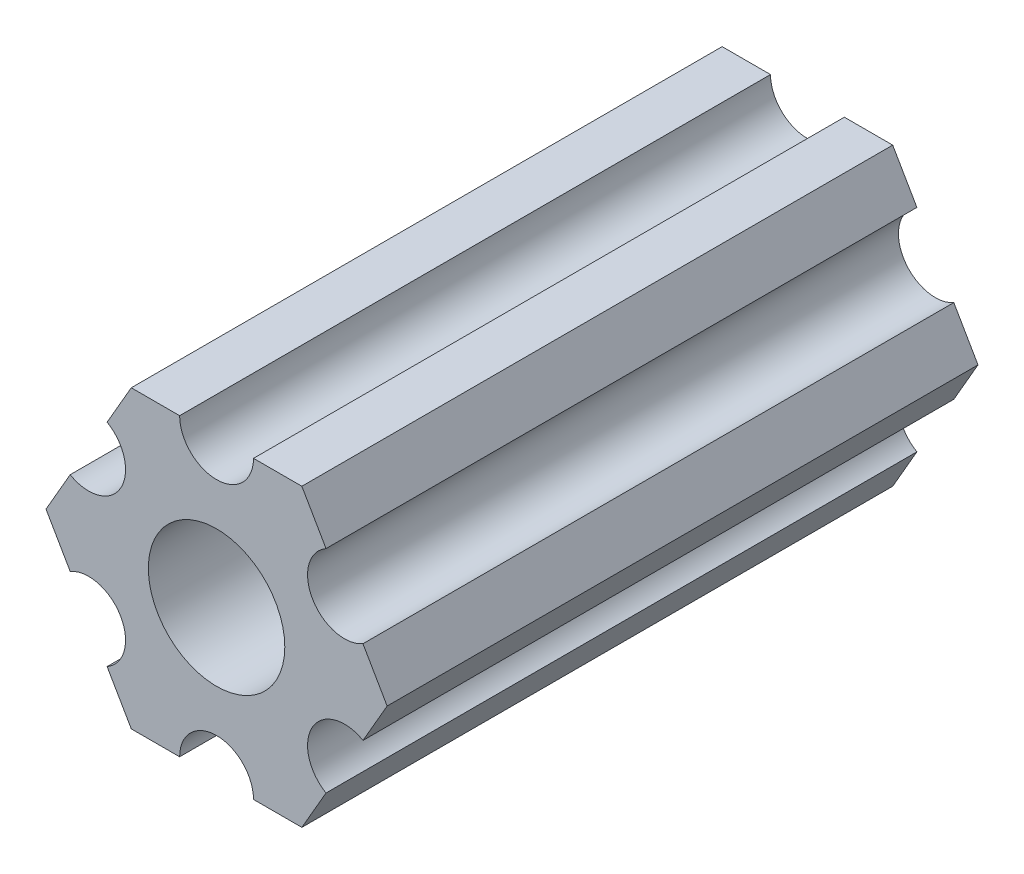
from build123d import *

# Parameters (mm, degrees)
SKETCH1_R           = 2.9337
BOSS_EXTRUDE1_DEPTH = 25.4


with BuildPart() as part:
    # Sketch1 → Boss-Extrude1 (new body)
    with BuildSketch(Plane.XY):
        with BuildLine():
            Line((-4.705511314, -4.549815329), (-3.666174209, -6.35))
            Line((-3.666174209, -6.35), (-1.5875, -6.35))
            ThreePointArc((-1.5875, -6.35), (0, -4.7625), (1.5875, -6.35))
            Line((1.5875, -6.35), (3.666174209, -6.35))
            Line((3.666174209, -6.35), (4.705511314, -4.549815329))
            ThreePointArc((4.705511314, -4.549815329), (4.124445986, -2.38125), (6.293011314, -1.800184671))
            Line((6.293011314, -1.800184671), (7.332348419, 0))
            Line((7.332348419, 0), (6.293011314, 1.800184671))
            ThreePointArc((6.293011314, 1.800184671), (4.124445986, 2.38125), (4.705511314, 4.549815329))
            Line((4.705511314, 4.549815329), (3.666174209, 6.35))
            Line((3.666174209, 6.35), (1.5875, 6.35))
            ThreePointArc((1.5875, 6.35), (0, 4.7625), (-1.5875, 6.35))
            Line((-1.5875, 6.35), (-3.666174209, 6.35))
            Line((-3.666174209, 6.35), (-4.705511314, 4.549815329))
            ThreePointArc((-4.705511314, 4.549815329), (-4.124445986, 2.38125), (-6.293011314, 1.800184671))
            Line((-6.293011314, 1.800184671), (-7.332348419, 0))
            Line((-7.332348419, 0), (-6.293011314, -1.800184671))
            ThreePointArc((-6.293011314, -1.800184671), (-4.124445986, -2.38125), (-4.705511314, -4.549815329))
        make_face()
        Circle(SKETCH1_R, mode=Mode.SUBTRACT)
    extrude(amount=-BOSS_EXTRUDE1_DEPTH)


solid = part.part
